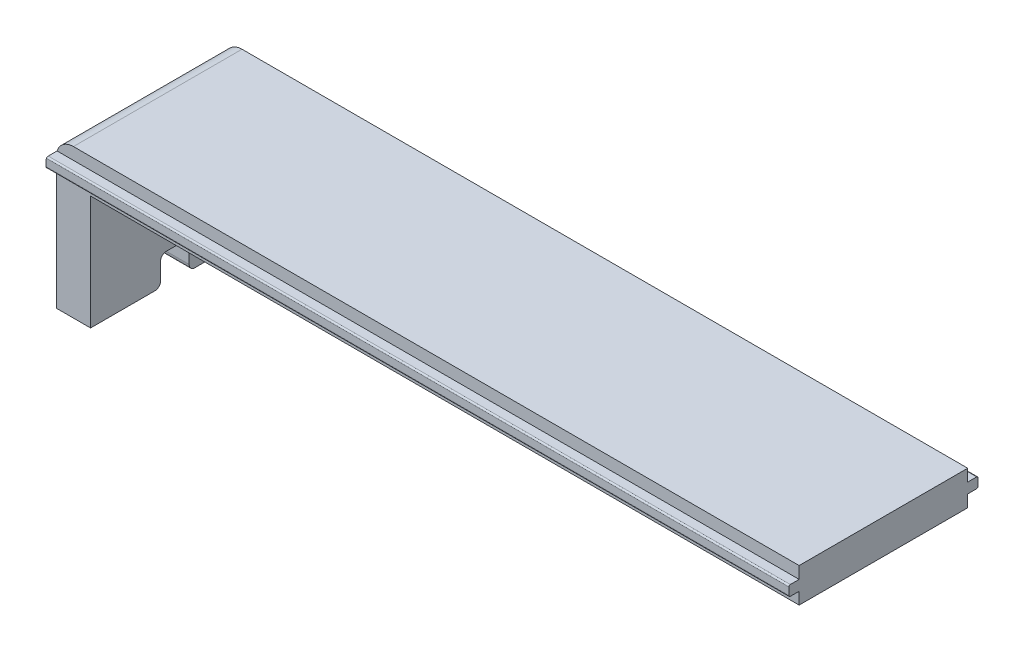
from build123d import *

# Parameters (mm, degrees)
BOSS_EXTRUDE1_DEPTH = 29.5
CUT_EXTRUDE1_REACH  = 132
SKETCH2_W           = 5
SKETCH2_H           = 5
SKETCH3_W           = 1.8
SKETCH3_H           = 1.8
BOSS_EXTRUDE2_DEPTH = 130
FILLET1_R           = 3
FILLET2_R           = 1
FILLET3_R           = 0.25


with BuildPart() as part:
    # Sketch1 → Boss-Extrude1 (new body)
    with BuildSketch(Plane.XY):
        Polygon((0, 0), (0, 26), (130, 26), (130, 20), (6, 20), (6, 0), align=None)
    extrude(amount=BOSS_EXTRUDE1_DEPTH)

    # Sketch2 → Cut-Extrude1 (cut, up to next)
    with BuildSketch(Plane.ZY, mode=Mode.PRIVATE) as cut_extrude1_sk1:
        with Locations((14.75, 2.5)):
            Rectangle(SKETCH2_W, SKETCH2_H)
    cut_extrude1_tool1 = extrude(cut_extrude1_sk1.sketch, amount=-CUT_EXTRUDE1_REACH, mode=Mode.PRIVATE) & part.part
    add(cut_extrude1_tool1.solids().sort_by_distance((0, 2.5, 14.75))[0], mode=Mode.SUBTRACT)

    # Sketch3 → Boss-Extrude2 (add)
    with BuildSketch(Plane.ZY):
        with Locations((-0.9, 23)):
            Rectangle(SKETCH3_W, SKETCH3_H)
        with Locations((30.4, 23)):
            Rectangle(SKETCH3_W, SKETCH3_H)
    extrude(amount=-BOSS_EXTRUDE2_DEPTH)

    # Fillet1
    fillet1_edges = [part.edges().sort_by_distance(p)[0] for p in [
        (0, 26, 14.75),
    ]]
    fillet(fillet1_edges, radius=FILLET1_R)

    # Fillet2
    fillet2_edges = [part.edges().sort_by_distance(p)[0] for p in [
        (3, 5, 17.25),
        (3, 0, 17.25),
        (3, 0, 12.25),
        (3, 5, 12.25),
        (0, 2.5, 17.25),
        (0, 5, 14.75),
        (0, 2.5, 12.25),
    ]]
    fillet(fillet2_edges, radius=FILLET2_R)

    # Fillet3
    fillet3_edges = [part.edges().sort_by_distance(p)[0] for p in [
        (65, 22.1, -1.8),
        (65.069091198, 23.9, -1.8),
        (65.069091198, 23.9, 31.3),
        (65, 22.1, 31.3),
    ]]
    fillet(fillet3_edges, radius=FILLET3_R)


solid = part.part
